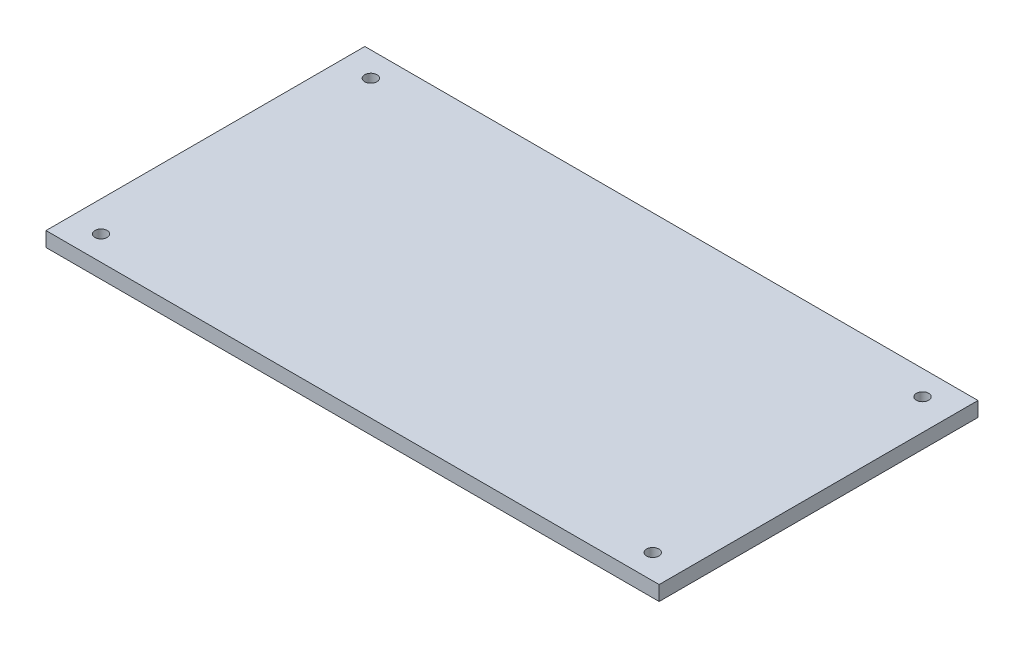
from build123d import *

# Parameters (mm, degrees)
SKETCH1_W           = 250
SKETCH1_H           = 130
BOSS_EXTRUDE1_DEPTH = 6
SKETCH1_4_R         = 2.5
CUT_EXTRUDE1_DEPTH  = 6


with BuildPart() as part:
    # Sketch1 → Boss-Extrude1 (new body)
    with BuildSketch(Plane(origin=(0, 0, 0), x_dir=(1, 0, 0), z_dir=(0, 1, 0))):
        Rectangle(SKETCH1_W, SKETCH1_H)
    extrude(amount=BOSS_EXTRUDE1_DEPTH)

    # Sketch1_4 → Cut-Extrude1 (cut)
    with BuildSketch(Plane(origin=(0, 0, 0), x_dir=(1, 0, 0), z_dir=(0, 1, 0))):
        with Locations((-112.568736162, 55)):
            Circle(SKETCH1_4_R)
        with Locations((112.379080965, 55)):
            Circle(SKETCH1_4_R)
        with Locations((112.379080965, -55)):
            Circle(SKETCH1_4_R)
        with Locations((-112.568736162, -55)):
            Circle(SKETCH1_4_R)
    extrude(amount=CUT_EXTRUDE1_DEPTH, mode=Mode.SUBTRACT)


solid = part.part
